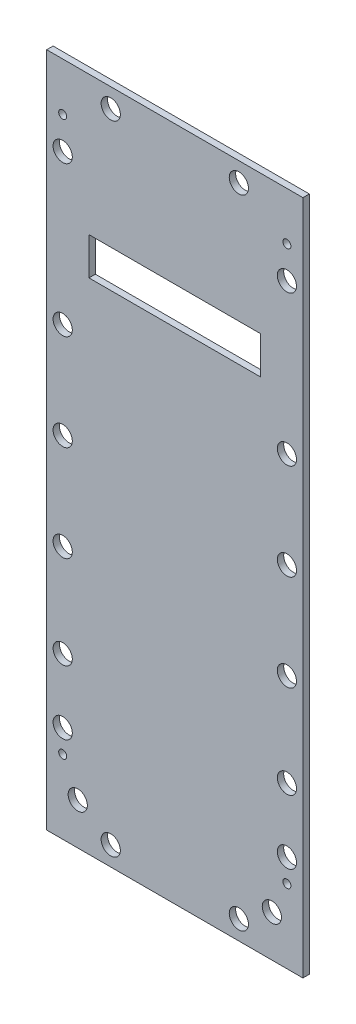
from build123d import *

# Parameters (mm, degrees)
SKETCH2_W                 = 80
SKETCH2_H                 = 211
SKETCH2_W_2               = 53.6
SKETCH2_H_2               = 11.7
BOSS_EXTRUDE1_DEPTH       = 2
M3X0_5_TAPPED_HOLE1_D     = 2.5
M3X0_5_TAPPED_HOLE1_DEPTH = 10
M3X0_5_TAPPED_HOLE1_TIP   = 0.751075774
SKETCH7_R                 = 3
CUT_EXTRUDE1_DEPTH        = 2


with BuildPart() as part:
    # Sketch2 → Boss-Extrude1 (new body)
    with BuildSketch(Plane.XY):
        with Locations((40, 105.5)):
            Rectangle(SKETCH2_W, SKETCH2_H)
        with Locations((40, 161.75)):
            Rectangle(SKETCH2_W_2, SKETCH2_H_2, mode=Mode.SUBTRACT)
    extrude(amount=BOSS_EXTRUDE1_DEPTH)

    # M3x0.5 Tapped Hole1
    with Locations(Plane(origin=(0, 0, 0), x_dir=(-1, 0, 0), z_dir=(0, 0, -1))):
        with Locations((-75, 196), (-5, 196), (-75, 23), (-5, 23)):
            Hole(M3X0_5_TAPPED_HOLE1_D / 2, depth=M3X0_5_TAPPED_HOLE1_DEPTH)
            with Locations((0, 0, -(M3X0_5_TAPPED_HOLE1_DEPTH + M3X0_5_TAPPED_HOLE1_TIP / 2))):  # 118° drill point
                Cone(0, M3X0_5_TAPPED_HOLE1_D / 2, M3X0_5_TAPPED_HOLE1_TIP, mode=Mode.SUBTRACT)

    # Sketch7 → Cut-Extrude1 (cut)
    with BuildSketch(Plane(origin=(0, 0, 0), x_dir=(-1, 0, 0), z_dir=(0, 0, -1))):
        with Locations((-75, 186)):
            Circle(SKETCH7_R)
        with Locations((-75, 139.2)):
            Circle(SKETCH7_R)
        with Locations((-75, 109.2)):
            Circle(SKETCH7_R)
        with Locations((-75, 79.2)):
            Circle(SKETCH7_R)
        with Locations((-75, 50.2)):
            Circle(SKETCH7_R)
        with Locations((-75, 30.2)):
            Circle(SKETCH7_R)
        with Locations((-5, 186)):
            Circle(SKETCH7_R)
        with Locations((-5, 139.2)):
            Circle(SKETCH7_R)
        with Locations((-5, 109.2)):
            Circle(SKETCH7_R)
        with Locations((-5, 79.2)):
            Circle(SKETCH7_R)
        with Locations((-5, 50.2)):
            Circle(SKETCH7_R)
        with Locations((-5, 30.2)):
            Circle(SKETCH7_R)
        with Locations((-70.3, 13)):
            Circle(SKETCH7_R)
        with Locations((-60, 205)):
            Circle(SKETCH7_R)
        with Locations((-20, 205)):
            Circle(SKETCH7_R)
        with Locations((-60, 6)):
            Circle(SKETCH7_R)
        with Locations((-20, 6)):
            Circle(SKETCH7_R)
        with Locations((-9.7, 13)):
            Circle(SKETCH7_R)
    extrude(amount=-CUT_EXTRUDE1_DEPTH, mode=Mode.SUBTRACT)


solid = part.part
